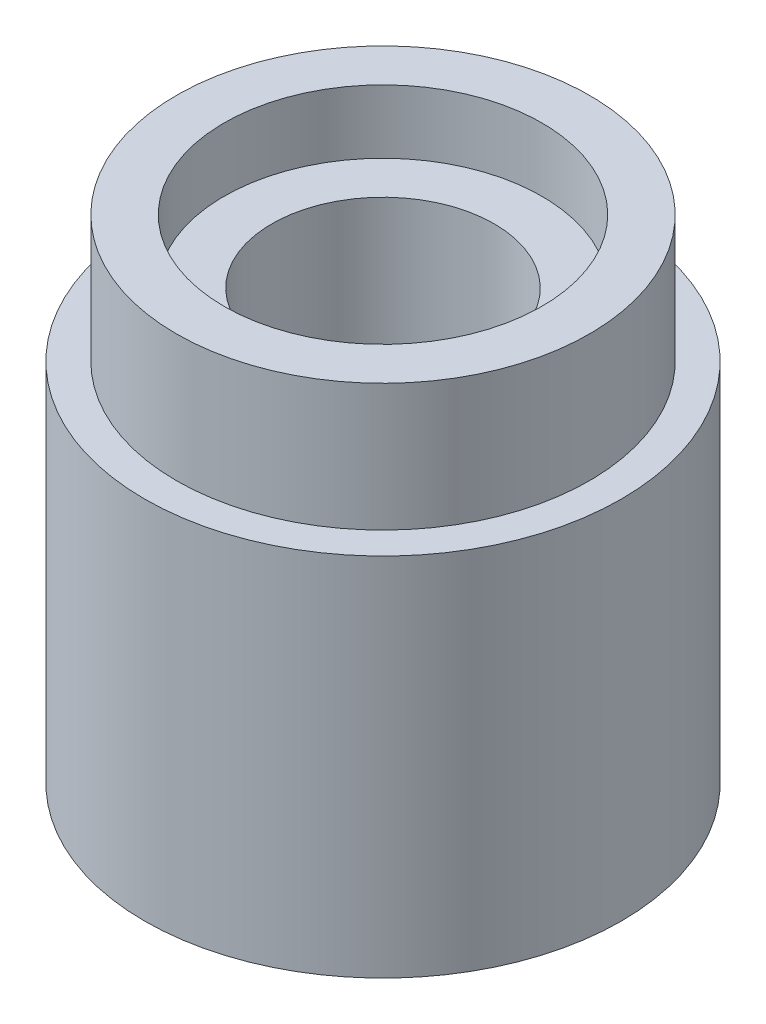
from build123d import *

# Parameters (mm, degrees)
SKETCH1_R           = 3.75
BOSS_EXTRUDE1_DEPTH = 7.75
SKETCH3_R           = 3.75
SKETCH3_R_2         = 3.25
CUT_EXTRUDE1_DEPTH  = 2
SKETCH4_R           = 1.75
CUT_EXTRUDE2_DEPTH  = 7.25
SKETCH5_R           = 2.5
CUT_EXTRUDE3_DEPTH  = 1


with BuildPart() as part:
    # Sketch1 → Boss-Extrude1 (new body)
    with BuildSketch(Plane(origin=(0, 0, 0), x_dir=(1, 0, 0), z_dir=(0, 1, 0))):
        Circle(SKETCH1_R)
    extrude(amount=BOSS_EXTRUDE1_DEPTH)

    # Sketch3 → Cut-Extrude1 (cut)
    with BuildSketch(Plane(origin=(0, 7.75, 0), x_dir=(1, 0, 0), z_dir=(0, 1, 0))):
        Circle(SKETCH3_R)
        Circle(SKETCH3_R_2, mode=Mode.SUBTRACT)
    extrude(amount=-CUT_EXTRUDE1_DEPTH, mode=Mode.SUBTRACT)

    # Sketch4 → Cut-Extrude2 (cut)
    with BuildSketch(Plane(origin=(0, 7.75, 0), x_dir=(1, 0, 0), z_dir=(0, 1, 0))):
        Circle(SKETCH4_R)
    extrude(amount=-CUT_EXTRUDE2_DEPTH, mode=Mode.SUBTRACT)

    # Sketch5 → Cut-Extrude3 (cut)
    with BuildSketch(Plane(origin=(0, 7.75, 0), x_dir=(1, 0, 0), z_dir=(0, 1, 0))):
        Circle(SKETCH5_R)
    extrude(amount=-CUT_EXTRUDE3_DEPTH, mode=Mode.SUBTRACT)


solid = part.part
